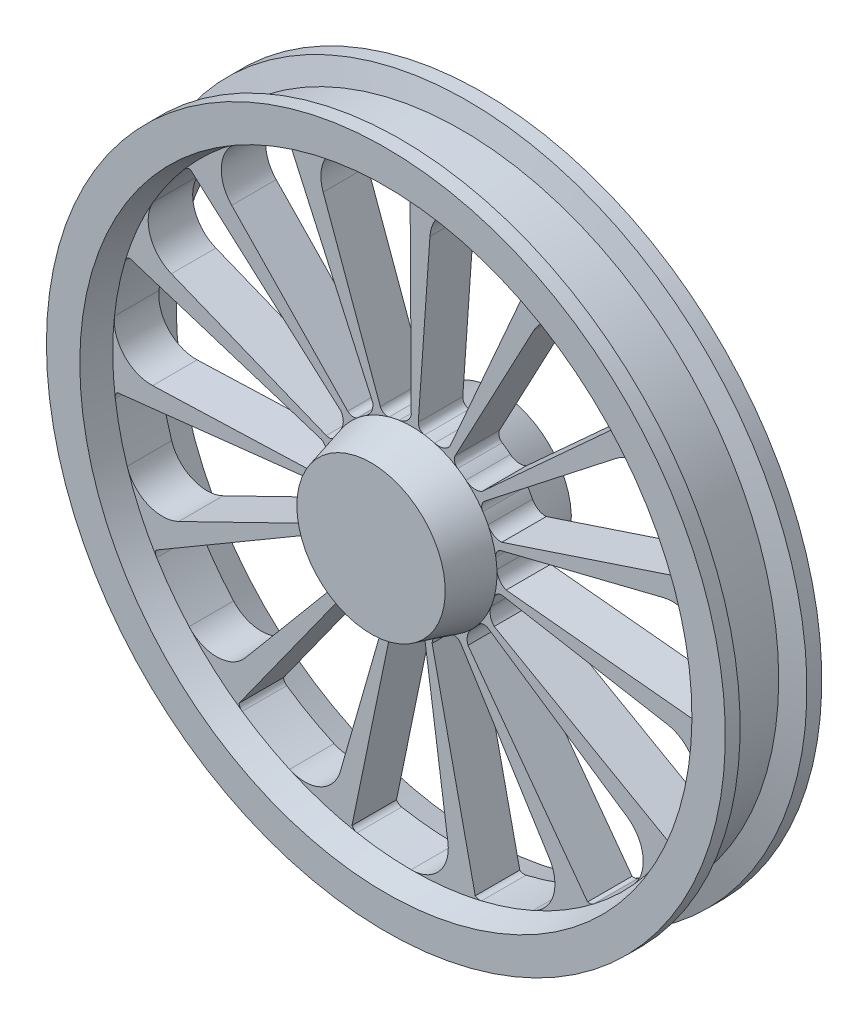
from build123d import *

# Parameters (mm, degrees)
CUT_EXTRUDE1_DEPTH = 100


with BuildPart() as part:
    # Sketch3 → Revolve1 (revolve)
    with BuildSketch(Plane(origin=(0, 0, 0), x_dir=(0, 0, -1), z_dir=(1, 0, 0))):
        Polygon((-85, -159.783995886), (-85, -259.783995886), (85, -259.783995886), (85, -159.783995886), (30, -145.046790303), (30, 143.337782379), (65, 152.716004114), (65, 197.716004114), (45, 197.716004114), (36.961524227, 167.716004114), (-36.961524227, 167.716004114), (-45, 197.716004114), (-65, 197.716004114), (-65, 152.716004114), (-30, 143.337782379), (-30, -145.046790303), align=None)
    revolve(axis=Axis((0, -259.783995886, -85), (0, 0, 1)))

    # Sketch4 → Cut-Extrude1 (cut)
    with BuildSketch(Plane(origin=(0, 0, -30), x_dir=(-1, 0, 0), z_dir=(0, 0, -1))):
        with BuildLine():
            ThreePointArc((-72.925631177, -171.203644439), (-67.490960057, -166.996083658), (-61.814108105, -163.121477896))
            ThreePointArc((-61.814108105, -163.121477896), (-57.528920322, -157.234516569), (-58.372083247, -150.002074086))
            Line((-58.372083247, -150.002074086), (-164.110357501, 48.862696703))
            ThreePointArc((-164.110357501, 48.862696703), (-197.069759166, 74.121337359), (-237.745827367, 65.767981041))
            ThreePointArc((-237.745827367, 65.767981041), (-266.278996837, 42.875324068), (-292.619409606, 17.490325379))
            ThreePointArc((-292.619409606, 17.490325379), (-294.860692802, 13.734289934), (-295.284494064, 9.380952694))
            Line((-295.284494064, 9.380952694), (-94.383246489, -173.749469189))
            ThreePointArc((-94.383246489, -173.749469189), (-83.281037917, -175.623785707), (-72.925631177, -171.203644439))
        make_face()
        with BuildLine():
            ThreePointArc((-102.649753898, -208.523344604), (-99.39630393, -202.469066678), (-95.786185757, -196.620454477))
            ThreePointArc((-95.786185757, -196.620454477), (-94.265914809, -189.499504804), (-97.977881847, -183.235285084))
            Line((-97.977881847, -183.235285084), (-275.460191287, -44.570907759))
            ThreePointArc((-275.460191287, -44.570907759), (-315.843717675, -34.901787712), (-349.605538906, -59.077405866))
            ThreePointArc((-349.605538906, -59.077405866), (-366.36060382, -91.596374224), (-380.098759106, -125.500335536))
            ThreePointArc((-380.098759106, -125.500335536), (-380.618555941, -129.843256659), (-379.235055884, -133.992603622))
            Line((-379.235055884, -133.992603622), (-121.216780685, -219.576669661))
            ThreePointArc((-121.216780685, -219.576669661), (-110.312055265, -216.773267957), (-102.649753898, -208.523344604))
        make_face()
        with BuildLine():
            ThreePointArc((-114.624801626, -254.706477064), (-114.115123866, -247.852321647), (-113.1959617, -241.040981191))
            ThreePointArc((-113.1959617, -241.040981191), (-114.703476248, -233.917320061), (-120.642414575, -229.704463602))
            Line((-120.642414575, -229.704463602), (-339.180455522, -175.216810307))
            ThreePointArc((-339.180455522, -175.216810307), (-380.005428047, -182.809089568), (-401.015276703, -218.62678555))
            ThreePointArc((-401.015276703, -218.62678555), (-403.09513412, -255.149240238), (-401.855580068, -291.709861254))
            ThreePointArc((-401.855580068, -291.709861254), (-400.564012946, -295.888737538), (-397.612431299, -299.11663444))
            Line((-397.612431299, -299.11663444), (-127.090832281, -272.356082109))
            ThreePointArc((-127.090832281, -272.356082109), (-118.269116105, -265.359695806), (-114.624801626, -254.706477064))
        make_face()
        with BuildLine():
            ThreePointArc((-106.780179819, -301.767558657), (-109.102402183, -295.298671489), (-111.033127513, -288.702345421))
            ThreePointArc((-111.033127513, -288.702345421), (-115.307764594, -282.80771856), (-122.44677782, -281.374666517))
            Line((-122.44677782, -281.374666517), (-344.25333764, -320.485147511))
            ThreePointArc((-344.25333764, -320.485147511), (-378.460747669, -344.026052021), (-383.085830047, -385.292620802))
            ThreePointArc((-383.085830047, -385.292620802), (-370.130853727, -419.503497609), (-354.127920493, -452.399114812))
            ThreePointArc((-354.127920493, -452.399114812), (-351.248313104, -455.691380584), (-347.239005147, -457.439694726))
            Line((-347.239005147, -457.439694726), (-110.989724392, -322.961666636))
            ThreePointArc((-110.989724392, -322.961666636), (-105.776372329, -312.982034486), (-106.780179819, -301.767558657))
        make_face()
        with BuildLine():
            ThreePointArc((-80.472294854, -341.569300838), (-85.224883997, -336.604211278), (-89.671656875, -331.363464301))
            ThreePointArc((-89.671656875, -331.363464301), (-95.974292905, -327.717106245), (-103.078980787, -329.311646334))
            Line((-103.078980787, -329.311646334), (-289.801690237, -455.257704146))
            ThreePointArc((-289.801690237, -455.257704146), (-311.476765811, -490.676797653), (-298.917363152, -530.256874597))
            ThreePointArc((-298.917363152, -530.256874597), (-273.167586192, -556.240802126), (-245.168326313, -579.783464455))
            ThreePointArc((-245.168326313, -579.783464455), (-241.198588935, -581.619857053), (-236.824800438, -581.586289037))
            Line((-236.824800438, -581.586289037), (-75.697484845, -362.643257939))
            ThreePointArc((-75.697484845, -362.643257939), (-74.993932829, -351.405949002), (-80.472294854, -341.569300838))
        make_face()
        with BuildLine():
            ThreePointArc((-40.250019041, -367.229620796), (-46.611209125, -364.626837936), (-52.805142121, -361.647842813))
            ThreePointArc((-52.805142121, -361.647842813), (-60.045994073, -360.880241995), (-65.887891532, -365.22666375))
            Line((-65.887891532, -365.22666375), (-185.240697826, -556.2310808))
            ThreePointArc((-185.240697826, -556.2310808), (-190.635621467, -597.404080265), (-163.063368588, -628.453910493))
            ThreePointArc((-163.063368588, -628.453910493), (-128.971161354, -641.718031618), (-93.81690123, -651.836998878))
            ThreePointArc((-93.81690123, -651.836998878), (-89.443437519, -651.89998934), (-85.461436247, -650.09034338))
            Line((-85.461436247, -650.09034338), (-27.316462478, -384.539548386))
            ThreePointArc((-27.316462478, -384.539548386), (-31.244361044, -373.987595465), (-40.250019041, -367.229620796))
        make_face()
        with BuildLine():
            ThreePointArc((25.787824413, -384.864470437), (17.907644611, -376.822402054), (6.931850724, -374.311616095))
            ThreePointArc((6.931850724, -374.311616095), (0.061967254, -374.521184736), (-6.808138575, -374.319036788))
            ThreePointArc((-6.808138575, -374.319036788), (-13.735197365, -376.562918363), (-17.304187259, -382.909685976))
            Line((-17.304187259, -382.909685976), (-48.649905902, -605.946063336))
            ThreePointArc((-48.649905902, -605.946063336), (-36.8318463, -645.753783105), (0.985763789, -662.904568893))
            ThreePointArc((0.985763789, -662.904568893), (37.525548948, -661.155396571), (73.756318376, -656.101007395))
            ThreePointArc((73.756318376, -656.101007395), (77.777296813, -654.379704096), (80.678986664, -651.10688442))
            Line((80.678986664, -651.10688442), (25.787824413, -384.864470437))
        make_face()
        with BuildLine():
            ThreePointArc((74.433162188, -363.561842118), (63.963255827, -359.420204956), (52.915140525, -361.590745409))
            ThreePointArc((52.915140525, -361.590745409), (46.724428933, -364.57642923), (40.366053981, -367.186081672))
            ThreePointArc((40.366053981, -367.186081672), (34.950539748, -372.053458132), (34.271568195, -379.303157824))
            Line((34.271568195, -379.303157824), (96.352896723, -595.806479625))
            ThreePointArc((96.352896723, -595.806479625), (123.340489698, -627.36580331), (164.864448651, -627.652017985))
            ThreePointArc((164.864448651, -627.652017985), (197.533750928, -611.192000001), (228.57640048, -591.838204194))
            ThreePointArc((228.57640048, -591.838204194), (231.54962994, -588.630236114), (232.869279835, -584.460142975))
            Line((232.869279835, -584.460142975), (74.433162188, -363.561842118))
        make_face()
        with BuildLine():
            ThreePointArc((110.208330017, -324.315081394), (98.959039023, -324.790002144), (89.748921811, -331.266562845))
            ThreePointArc((89.748921811, -331.266562845), (85.30781237, -336.512109989), (80.560589089, -341.482330207))
            ThreePointArc((80.560589089, -341.482330207), (77.593011023, -348.131587942), (79.921458161, -355.030680775))
            Line((79.921458161, -355.030680775), (224.695408166, -527.565555808))
            ThreePointArc((224.695408166, -527.565555808), (262.186134514, -545.419589635), (300.236572595, -528.791744079))
            ThreePointArc((300.236572595, -528.791744079), (323.386572835, -500.466967078), (343.873546389, -470.16021176))
            ThreePointArc((343.873546389, -470.16021176), (345.284928489, -466.020265722), (344.794358971, -461.673946109))
            Line((344.794358971, -461.673946109), (110.208330017, -324.315081394))
        make_face()
        with BuildLine():
            ThreePointArc((126.927476375, -273.910309738), (116.843905357, -278.919670288), (111.064299172, -288.582395055))
            ThreePointArc((111.064299172, -288.582395055), (109.140700052, -295.180802767), (106.825466474, -301.652194532))
            ThreePointArc((106.825466474, -301.652194532), (106.818945781, -308.933616473), (111.752201947, -314.28918662))
            Line((111.752201947, -314.28918662), (314.186042243, -413.022767561))
            ThreePointArc((314.186042243, -413.022767561), (355.697414787, -414.084386883), (383.695065574, -383.417586653))
            ThreePointArc((383.695065574, -383.417586653), (393.322918424, -348.125661899), (399.711832135, -312.106260392))
            ThreePointArc((399.711832135, -312.106260392), (399.317326087, -307.750170677), (397.101361083, -303.979142736))
            Line((397.101361083, -303.979142736), (126.927476375, -273.910309738))
        make_face()
        with BuildLine():
            ThreePointArc((121.699708967, -221.062970084), (114.525398961, -229.740606486), (113.175650218, -240.918722424))
            ThreePointArc((113.175650218, -240.918722424), (114.102169183, -247.729066065), (114.619250226, -254.58266695))
            ThreePointArc((114.619250226, -254.58266695), (117.574914394, -261.237229094), (124.259974779, -264.123249823))
            Line((124.259974779, -264.123249823), (349.351055326, -271.983603561))
            ThreePointArc((349.351055326, -271.983603561), (387.705380633, -256.069244753), (400.809195955, -216.666058207))
            ThreePointArc((400.809195955, -216.666058207), (395.250158191, -180.509280108), (386.436310836, -145.005314159))
            ThreePointArc((386.436310836, -145.005314159), (384.30413032, -141.186288252), (380.745930311, -138.642596973))
            Line((380.745930311, -138.642596973), (121.699708967, -221.062970084))
        make_face()
        with BuildLine():
            ThreePointArc((95.428956272, -174.910847561), (92.404410655, -185.756317647), (95.717903174, -196.51702696))
            ThreePointArc((95.717903174, -196.51702696), (99.334336676, -202.361736245), (102.594324332, -208.412496394))
            ThreePointArc((102.594324332, -208.412496394), (108.001112174, -213.289564492), (115.282069106, -213.207016599))
            Line((115.282069106, -213.207016599), (324.110097188, -128.835016564))
            ThreePointArc((324.110097188, -128.835016564), (352.675563975, -98.696416841), (348.619775118, -57.3700129))
            ThreePointArc((348.619775118, -57.3700129), (328.835054871, -26.600216864), (306.34244073, 2.249355272))
            ThreePointArc((306.34244073, 2.249355272), (302.841259128, 4.870973096), (298.55606922, 5.747500383))
            Line((298.55606922, 5.747500383), (95.428956272, -174.910847561))
        make_face()
        with BuildLine():
            ThreePointArc((52.657670093, -143.434063431), (54.305860278, -154.572086896), (61.709661101, -163.054765185))
            ThreePointArc((61.709661101, -163.054765185), (67.390694934, -166.923236782), (72.82990772, -171.124924796))
            ThreePointArc((72.82990772, -171.124924796), (79.7529365, -173.381209466), (86.370846379, -170.344366233))
            Line((86.370846379, -170.344366233), (242.827558799, -8.328697726))
            ThreePointArc((242.827558799, -8.328697726), (256.664938349, 30.822905219), (236.150828051, 66.926815876))
            ThreePointArc((236.150828051, 66.926815876), (205.561383192, 86.98925258), (173.279179588, 104.196077789))
            ThreePointArc((173.279179588, 104.196077789), (169.014383006, 105.166985993), (164.743151465, 104.224789756))
            Line((164.743151465, 104.224789756), (52.657670093, -143.434063431))
        make_face()
        with BuildLine():
            ThreePointArc((10.254374104, 143.207338913), (5.963384615, 142.359658647), (2.444646176, 139.761653175))
            Line((2.444646176, 139.761653175), (0.781394375, -132.075239629))
            ThreePointArc((0.781394375, -132.075239629), (6.817333306, -141.57995103), (17.031258009, -146.317866157))
            ThreePointArc((17.031258009, -146.317866157), (23.794589812, -147.541206181), (30.472538424, -149.167312031))
            ThreePointArc((30.472538424, -149.167312031), (37.714753572, -148.412681157), (42.525319659, -142.946640367))
            Line((42.525319659, -142.946640367), (119.557929474, 68.69871566))
            ThreePointArc((119.557929474, 68.69871566), (116.274613155, 110.093653997), (82.849257452, 134.732377223))
            ThreePointArc((82.849257452, 134.732377223), (46.744280892, 140.618477027), (10.254374104, 143.207338913))
        make_face()
        with BuildLine():
            ThreePointArc((-24.384352007, 88.928484048), (-44.220648976, 125.409196878), (-84.777702422, 134.322473591))
            ThreePointArc((-84.777702422, 134.322473591), (-120.155332232, 125.014476366), (-154.543505821, 112.537737189))
            ThreePointArc((-154.543505821, 112.537737189), (-158.118737152, 110.018040072), (-160.276560645, 106.213444114))
            Line((-160.276560645, 106.213444114), (-51.22999153, -142.798419982))
            ThreePointArc((-51.22999153, -142.798419982), (-41.849972528, -149.026368369), (-30.592004317, -149.200291766))
            ThreePointArc((-30.592004317, -149.200291766), (-23.915816055, -147.566973614), (-17.153809599, -146.336328826))
            ThreePointArc((-17.153809599, -146.336328826), (-10.844652876, -142.701264941), (-8.67322116, -135.751154705))
            Line((-8.67322116, -135.751154705), (-24.384352007, 88.928484048))
        make_face()
    extrude(amount=-CUT_EXTRUDE1_DEPTH, mode=Mode.SUBTRACT)


solid = part.part
